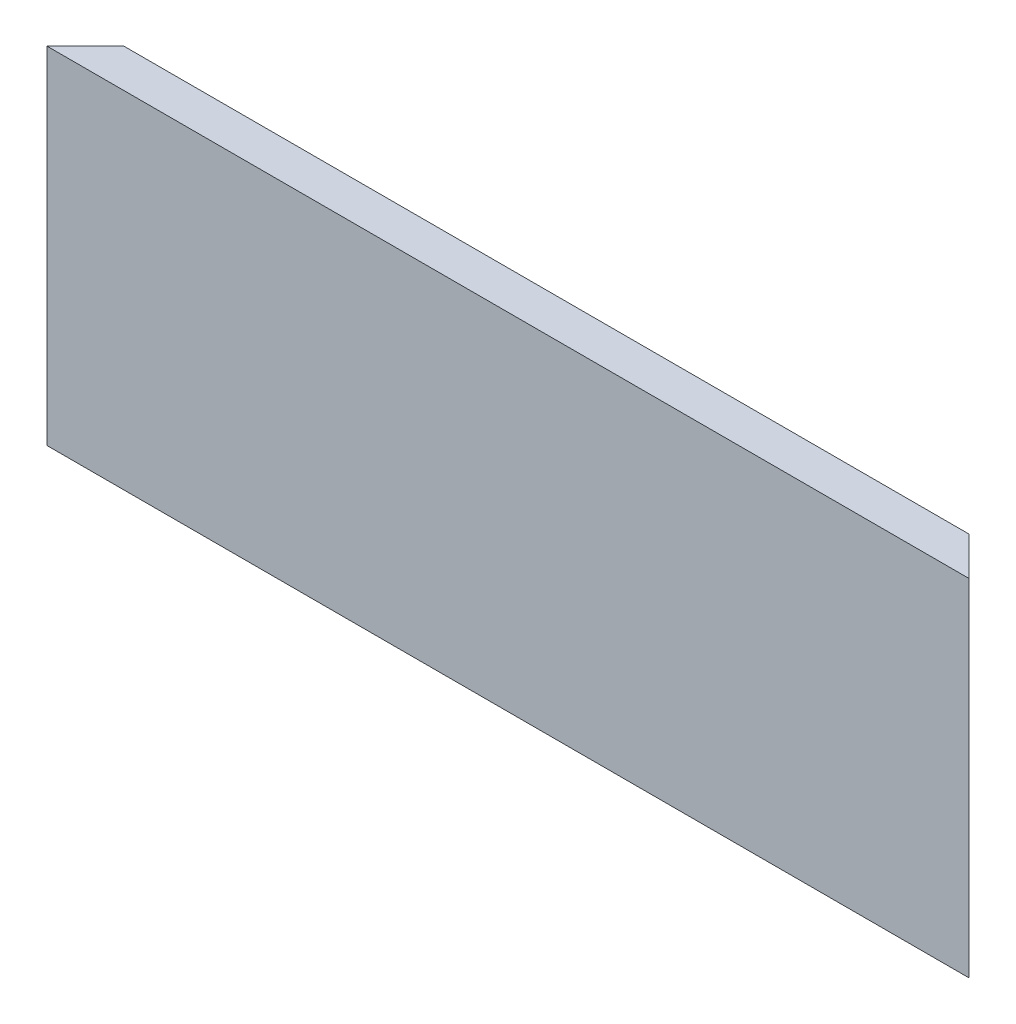
from build123d import *

# Parameters (mm, degrees)
SKETCH1_W           = 152.4
SKETCH1_H           = 57.15
BOSS_EXTRUDE1_DEPTH = 6.35
CUT_EXTRUDE2_DEPTH  = 58.15
SKETCH4_W           = 3.175
SKETCH4_H           = 4.7625
CUT_EXTRUDE3_DEPTH  = 153.4
SKETCH5_W           = 3.175
SKETCH5_H           = 3.2512
CUT_EXTRUDE4_DEPTH  = 153.4
SKETCH6_R           = 2.38125
CUT_EXTRUDE5_DEPTH  = 5.08


with BuildPart() as part:
    # Sketch1 → Boss-Extrude1 (new body)
    with BuildSketch(Plane.XY):
        with Locations((76.2, 28.575)):
            Rectangle(SKETCH1_W, SKETCH1_H)
    extrude(amount=-BOSS_EXTRUDE1_DEPTH)

    # Sketch3 → Cut-Extrude2 (cut, through all)
    with BuildSketch(Plane(origin=(0, 57.15, 0), x_dir=(1, 0, 0), z_dir=(0, 1, 0))):
        Polygon((152.4, 0), (146.05, 6.35), (152.4, 6.35), align=None)
        Polygon((0, 0), (6.35, 6.35), (0, 6.35), align=None)
    extrude(amount=-CUT_EXTRUDE2_DEPTH, mode=Mode.SUBTRACT)

    # Sketch4 → Cut-Extrude3 (cut, through all)
    with BuildSketch(Plane(origin=(0, 0, 0), x_dir=(0, 0, -1), z_dir=(1, 0, 0))):
        with Locations((4.7625, 43.97375)):
            Rectangle(SKETCH4_W, SKETCH4_H)
    extrude(amount=CUT_EXTRUDE3_DEPTH, mode=Mode.SUBTRACT)

    # Sketch5 → Cut-Extrude4 (cut, through all)
    with BuildSketch(Plane(origin=(0, 0, 0), x_dir=(0, 0, -1), z_dir=(1, 0, 0))):
        with Locations((4.7625, 6.3881)):
            Rectangle(SKETCH5_W, SKETCH5_H)
    extrude(amount=CUT_EXTRUDE4_DEPTH, mode=Mode.SUBTRACT)

    # Sketch6 → Cut-Extrude5 (cut)
    with BuildSketch(Plane(origin=(0, 0, -6.35), x_dir=(-1, 0, 0), z_dir=(0, 0, -1))):
        with Locations((-142.748, 49.911)):
            Circle(SKETCH6_R)
    extrude(amount=-CUT_EXTRUDE5_DEPTH, mode=Mode.SUBTRACT)


solid = part.part
